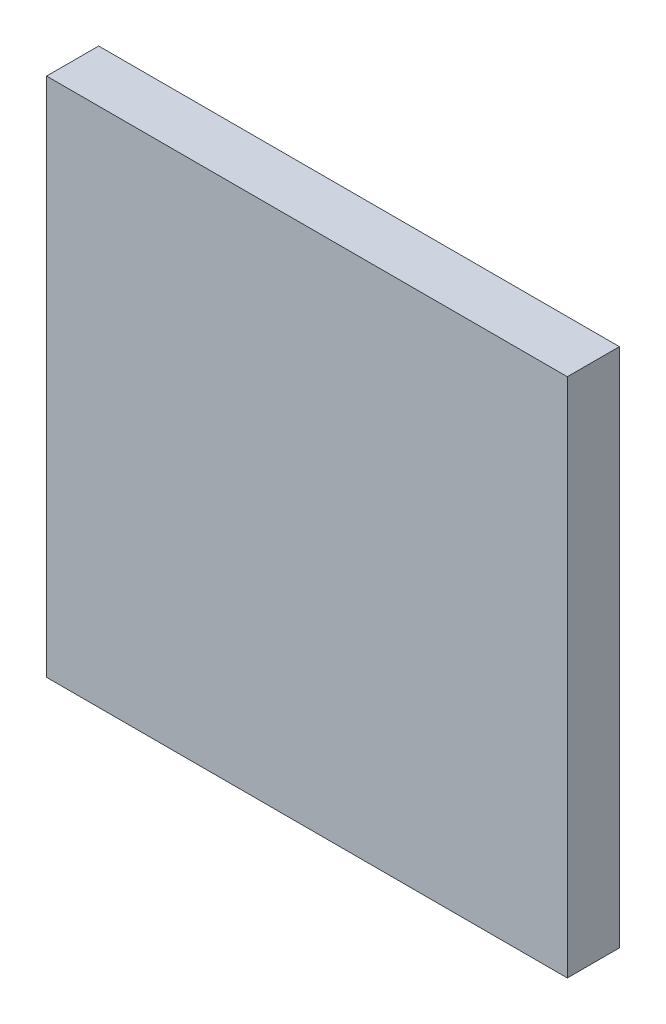
from build123d import *

# Parameters (mm, degrees)
ESQUISSE1_W        = 100
ESQUISSE1_H        = 100
BOSS_EXTRU_1_DEPTH = 10


with BuildPart() as part:
    # Esquisse1 → Boss.-Extru.1 (new body)
    with BuildSketch(Plane.XY):
        with Locations((50, 50)):
            Rectangle(ESQUISSE1_W, ESQUISSE1_H)
    extrude(amount=BOSS_EXTRU_1_DEPTH)


solid = part.part
